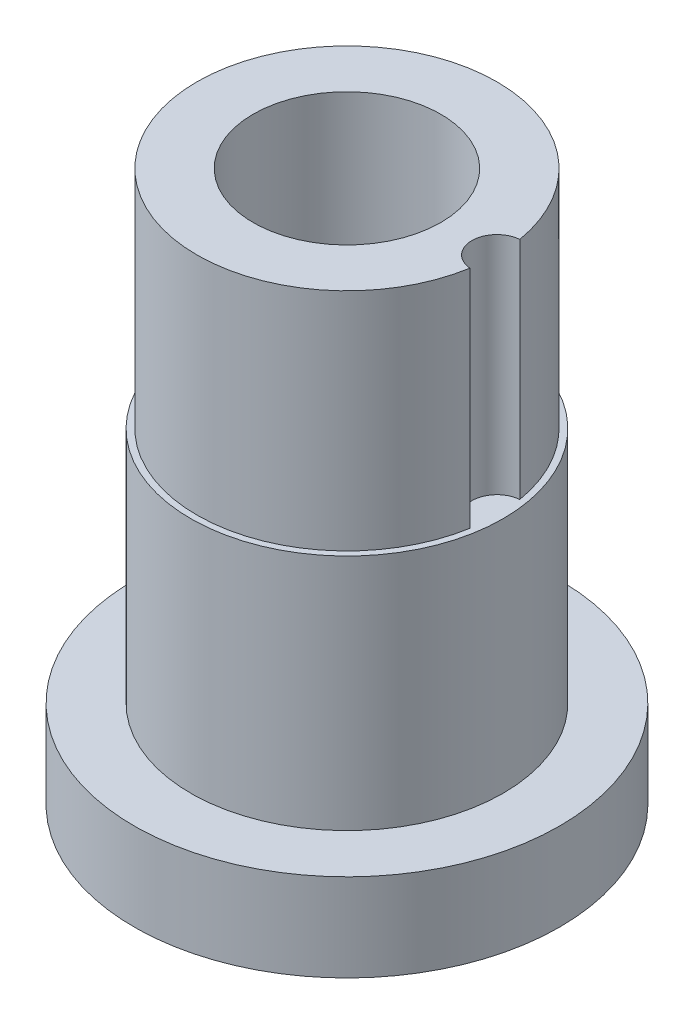
from build123d import *

# Parameters (mm, degrees)
SKETCH2_R          = 3.175
CUT_EXTRUDE1_DEPTH = 28.575


with BuildPart() as part:
    # Sketch1 → Revolve1 (revolve)
    with BuildSketch(Plane.XY):
        with BuildLine():
            Line((15.08125, -34.925), (26.9875, -34.925))
            Line((26.9875, -34.925), (26.9875, -23.8125))
            Line((26.9875, -23.8125), (19.812, -23.8125))
            Line((19.812, -23.8125), (19.812, 6.35))
            Line((19.812, 6.35), (19.0246, 6.35))
            Line((19.0246, 6.35), (19.0246, 34.925))
            Line((19.0246, 34.925), (11.90625, 34.925))
            Line((11.90625, 34.925), (11.90625, 3.175))
            ThreePointArc((11.90625, 3.175), (14.15131403, 2.24506403), (15.08125, 0))
            Line((15.08125, 0), (15.08125, -34.925))
        make_face()
    revolve(axis=Axis((0, -34.925, 0), (0, 1, 0)))

    # Sketch2 → Cut-Extrude1 (cut)
    with BuildSketch(Plane(origin=(0, 34.925, 0), x_dir=(1, 0, 0), z_dir=(0, 1, 0))):
        with Locations((19.0246, 0)):
            Circle(SKETCH2_R)
    extrude(amount=-CUT_EXTRUDE1_DEPTH, mode=Mode.SUBTRACT)


solid = part.part
